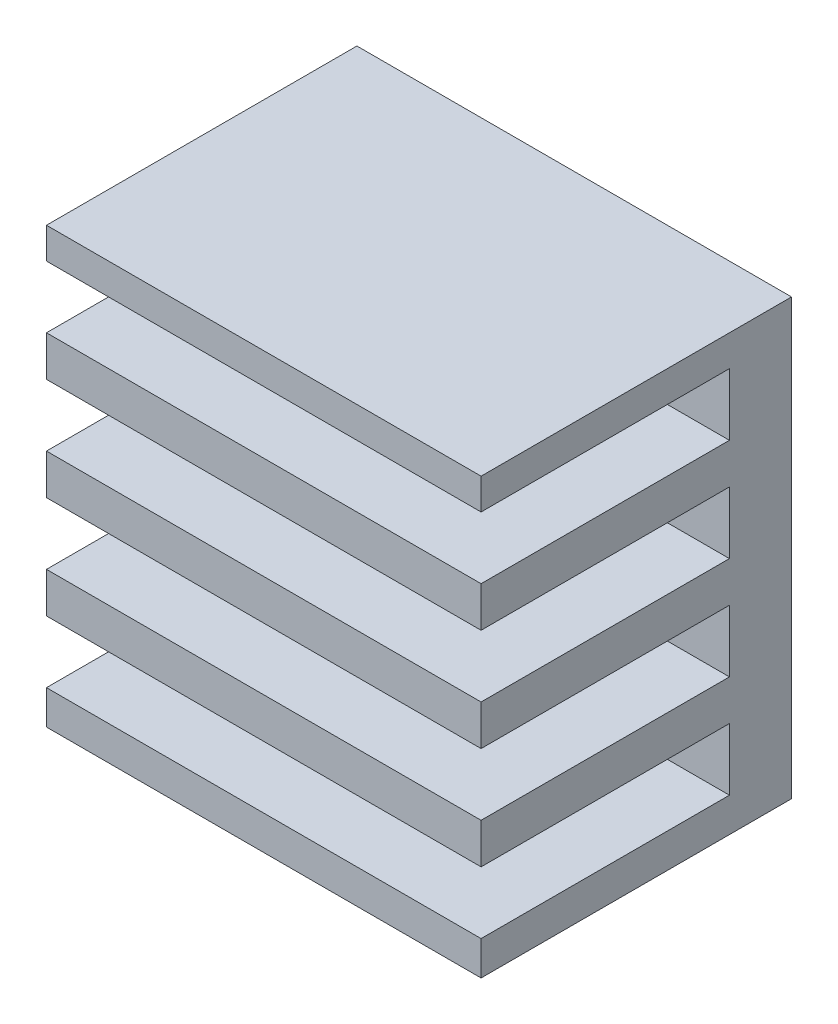
from build123d import *

# Parameters (mm, degrees)
SKETCH1_W           = 14
SKETCH1_H           = 14
BOSS_EXTRUDE1_DEPTH = 10
SKETCH2_W           = 8
SKETCH2_H           = 2
CUT_EXTRUDE1_DEPTH  = 15


with BuildPart() as part:
    # Sketch1 → Boss-Extrude1 (new body)
    with BuildSketch(Plane.XY):
        with Locations((23.5, 27.5)):
            Rectangle(SKETCH1_W, SKETCH1_H)
    extrude(amount=BOSS_EXTRUDE1_DEPTH)

    # Sketch2 → Cut-Extrude1 (cut, through all)
    with BuildSketch(Plane.ZY.offset(-16.5)):
        with Locations((6, 32.5)):
            Rectangle(SKETCH2_W, SKETCH2_H)
        with Locations((6, 29.2)):
            Rectangle(SKETCH2_W, SKETCH2_H)
        with Locations((6, 25.9)):
            Rectangle(SKETCH2_W, SKETCH2_H)
        with Locations((6, 22.6)):
            Rectangle(SKETCH2_W, SKETCH2_H)
    extrude(amount=-CUT_EXTRUDE1_DEPTH, mode=Mode.SUBTRACT)


solid = part.part
